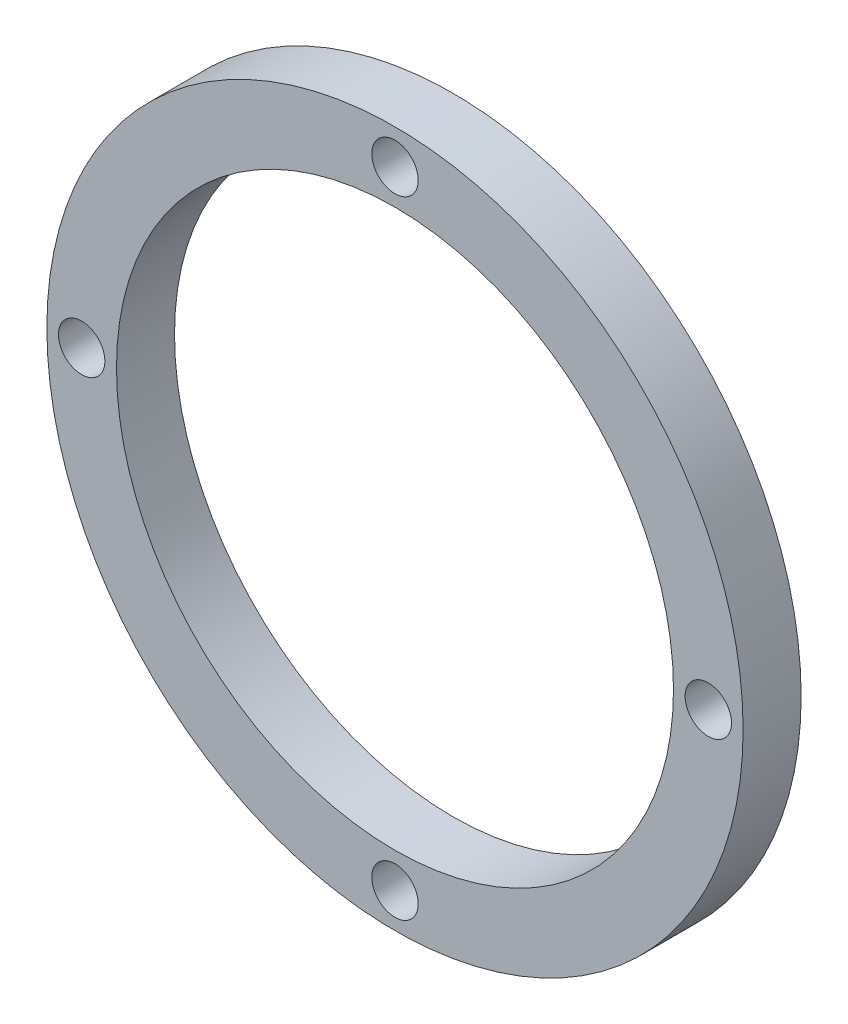
from build123d import *

# Parameters (mm, degrees)
SKETCH1_R           = 15
SKETCH1_R_2         = 12
SKETCH1_R_3         = 1
BOSS_EXTRUDE1_DEPTH = 1
SKETCH2_R           = 15
SKETCH2_R_2         = 12
SKETCH2_R_3         = 1
BOSS_EXTRUDE3_DEPTH = 1.5


with BuildPart() as part:
    # Sketch1 → Boss-Extrude1 (new body)
    with BuildSketch(Plane.XY):
        Circle(SKETCH1_R)
        Circle(SKETCH1_R_2, mode=Mode.SUBTRACT)
        with Locations((0, 13.5)):
            Circle(SKETCH1_R_3, mode=Mode.SUBTRACT)
        with Locations((13.5, 0)):
            Circle(SKETCH1_R_3, mode=Mode.SUBTRACT)
        with Locations((0, -13.5)):
            Circle(SKETCH1_R_3, mode=Mode.SUBTRACT)
        with Locations((-13.5, 0)):
            Circle(SKETCH1_R_3, mode=Mode.SUBTRACT)
    extrude(amount=BOSS_EXTRUDE1_DEPTH)

    # Sketch2 → Boss-Extrude3 (add)
    with BuildSketch(Plane.XY.offset(1)):
        Circle(SKETCH2_R)
        Circle(SKETCH2_R_2, mode=Mode.SUBTRACT)
        with Locations((0, 13.5)):
            Circle(SKETCH2_R_3, mode=Mode.SUBTRACT)
        with Locations((13.5, 0)):
            Circle(SKETCH2_R_3, mode=Mode.SUBTRACT)
        with Locations((0, -13.5)):
            Circle(SKETCH2_R_3, mode=Mode.SUBTRACT)
        with Locations((-13.5, 0)):
            Circle(SKETCH2_R_3, mode=Mode.SUBTRACT)
    extrude(amount=BOSS_EXTRUDE3_DEPTH)


solid = part.part
